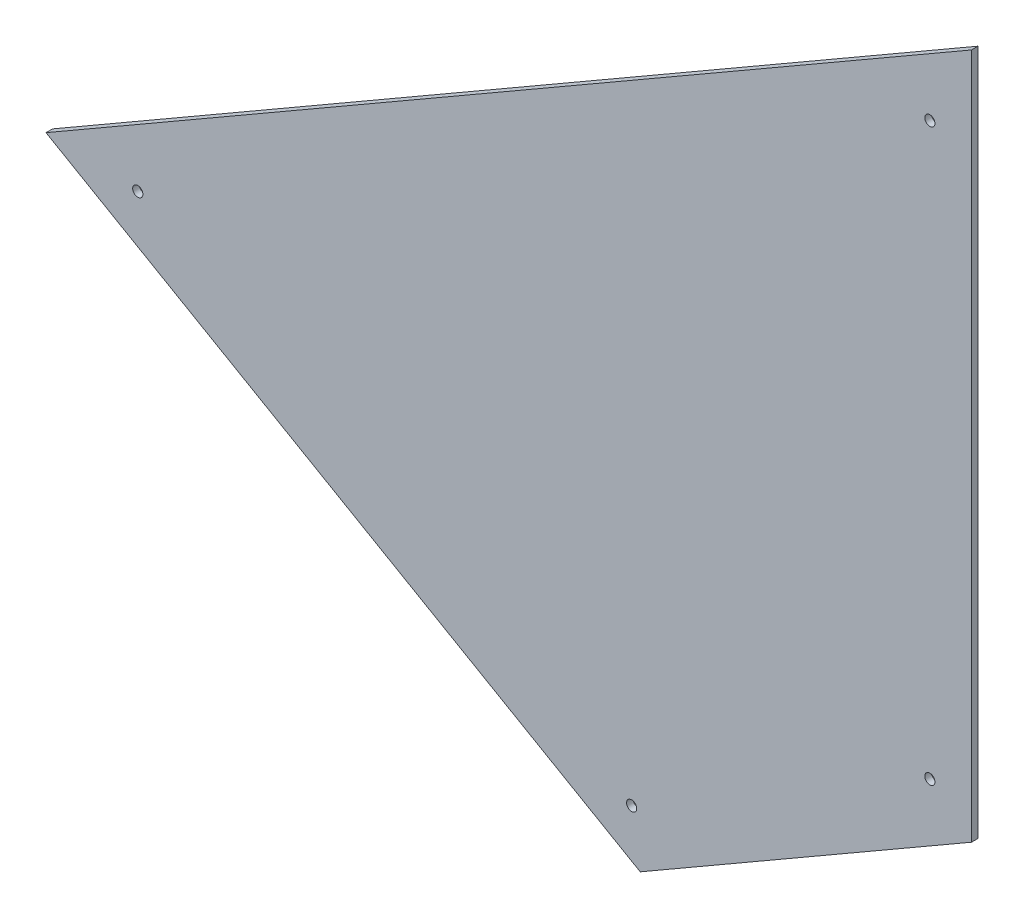
from build123d import *

# Parameters (mm, degrees)
EXTRUDE_1_DEPTH     = 2
SKETCH_4_R          = 1.55
CUT_EXTRUDE_1_DEPTH = 2


with BuildPart() as part:
    # Эскиз3 → Бобышка-Вытянуть1 (new body)
    with BuildSketch(Plane.XY):
        Polygon((0, -209.31740407), (-101.035924752, -267.65564884), (-282.318078778, -163.01074319), (0, 0), align=None)
    extrude(amount=EXTRUDE_1_DEPTH)

    # Эскиз4 → Вырез-Вытянуть1 (cut)
    with BuildSketch(Plane(origin=(0, 0, 0), x_dir=(-1, 0, 0), z_dir=(0, 0, -1))):
        with Locations((254.324370014, -164.525982342)):
            Circle(SKETCH_4_R)
        with Locations((103.664201466, -251.49438366)):
            Circle(SKETCH_4_R)
        with Locations((12.682716025, -198.961582281)):
            Circle(SKETCH_4_R)
        with Locations((12.682716025, -25.001847817)):
            Circle(SKETCH_4_R)
    extrude(amount=-CUT_EXTRUDE_1_DEPTH, mode=Mode.SUBTRACT)


solid = part.part
